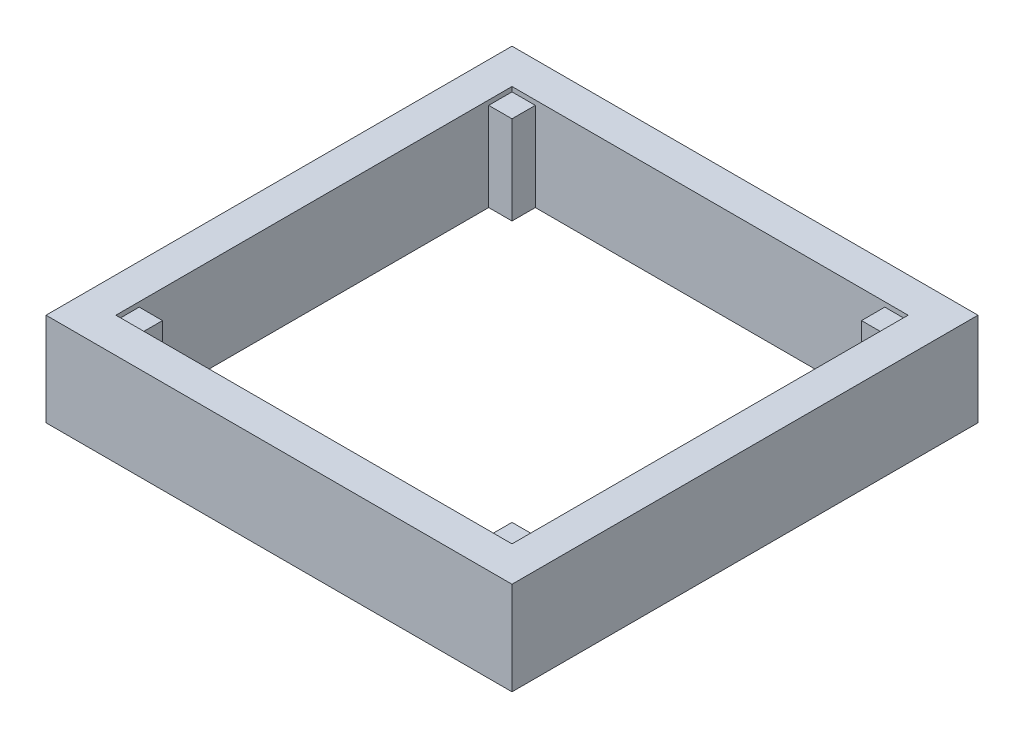
from build123d import *

# Parameters (mm, degrees)
SKETCH3_W               = 19.05
SKETCH3_H               = 215.9
BOSS_EXTRUDE1_DEPTH     = 50.8
SKETCH5_W               = 254
SKETCH5_H               = 19.05
BOSS_EXTRUDE2_DEPTH     = 50.8
SKETCH6_W               = 12.7
SKETCH6_H               = 12.7
BOSS_EXTRUDE3_DEPTH     = 48.26
MIRROR3_COPY_1_SKETCH_W = 19.05
MIRROR3_COPY_1_SKETCH_H = 215.9
MIRROR3_COPY_1_DEPTH    = 50.8
MIRROR3_COPY_2_SKETCH_W = 12.7
MIRROR3_COPY_2_SKETCH_H = 12.7
MIRROR3_COPY_2_DEPTH    = 48.26
MIRROR3_COPY_3_SKETCH_W = 19.05
MIRROR3_COPY_3_SKETCH_H = 215.9
MIRROR3_COPY_3_DEPTH    = 50.8


with BuildPart() as part:
    # Sketch3 → Boss-Extrude1 (new body)
    with BuildSketch(Plane(origin=(0, 0, 0), x_dir=(1, 0, 0), z_dir=(0, 1, 0))):
        with Locations((-117.475, 0)):
            Rectangle(SKETCH3_W, SKETCH3_H)
    boss_extrude1 = extrude(amount=BOSS_EXTRUDE1_DEPTH)

    # Sketch5 → Boss-Extrude2 (add)
    with BuildSketch(Plane(origin=(0, 0, 0), x_dir=(1, 0, 0), z_dir=(0, 1, 0))):
        with Locations((0, -117.475)):
            Rectangle(SKETCH5_W, SKETCH5_H)
    boss_extrude2 = extrude(amount=BOSS_EXTRUDE2_DEPTH)

    # Sketch6 → Boss-Extrude3 (add)
    with BuildSketch(Plane(origin=(0, 0, 0), x_dir=(1, 0, 0), z_dir=(0, 1, 0))):
        with Locations((-101.6, -101.6)):
            Rectangle(SKETCH6_W, SKETCH6_H)
    boss_extrude3 = extrude(amount=BOSS_EXTRUDE3_DEPTH)

    # Mirror2: Boss-Extrude1, Boss-Extrude3 across plane
    add(boss_extrude1.mirror(Plane(origin=(0, 0, 0), x_dir=(0, 0, 1), z_dir=(1, 0, 0))))
    add(boss_extrude3.mirror(Plane(origin=(0, 0, 0), x_dir=(0, 0, 1), z_dir=(1, 0, 0))))

    # Mirror3: Boss-Extrude3, Boss-Extrude2 across plane
    add(boss_extrude3.mirror(Plane.XY))
    add(boss_extrude2.mirror(Plane.XY))

    # Mirror3 copy 1 sketch → Mirror3 copy 1 (add)
    with BuildSketch(Plane(origin=(0, 0, 0), x_dir=(-1, 0, 0), z_dir=(0, 1, 0))):
        with Locations((-117.475, 0)):
            Rectangle(MIRROR3_COPY_1_SKETCH_W, MIRROR3_COPY_1_SKETCH_H)
    extrude(amount=MIRROR3_COPY_1_DEPTH)

    # Mirror3 copy 2 sketch → Mirror3 copy 2 (add)
    with BuildSketch(Plane(origin=(0, 0, 0), x_dir=(-1, 0, 0), z_dir=(0, 1, 0))):
        with Locations((-101.6, -101.6)):
            Rectangle(MIRROR3_COPY_2_SKETCH_W, MIRROR3_COPY_2_SKETCH_H)
    extrude(amount=MIRROR3_COPY_2_DEPTH)

    # Mirror3 copy 3 sketch → Mirror3 copy 3 (add)
    with BuildSketch(Plane(origin=(0, 0, 0), x_dir=(1, 0, 0), z_dir=(0, 1, 0))):
        with Locations((-117.475, 0)):
            Rectangle(MIRROR3_COPY_3_SKETCH_W, MIRROR3_COPY_3_SKETCH_H)
    extrude(amount=MIRROR3_COPY_3_DEPTH)


solid = part.part
